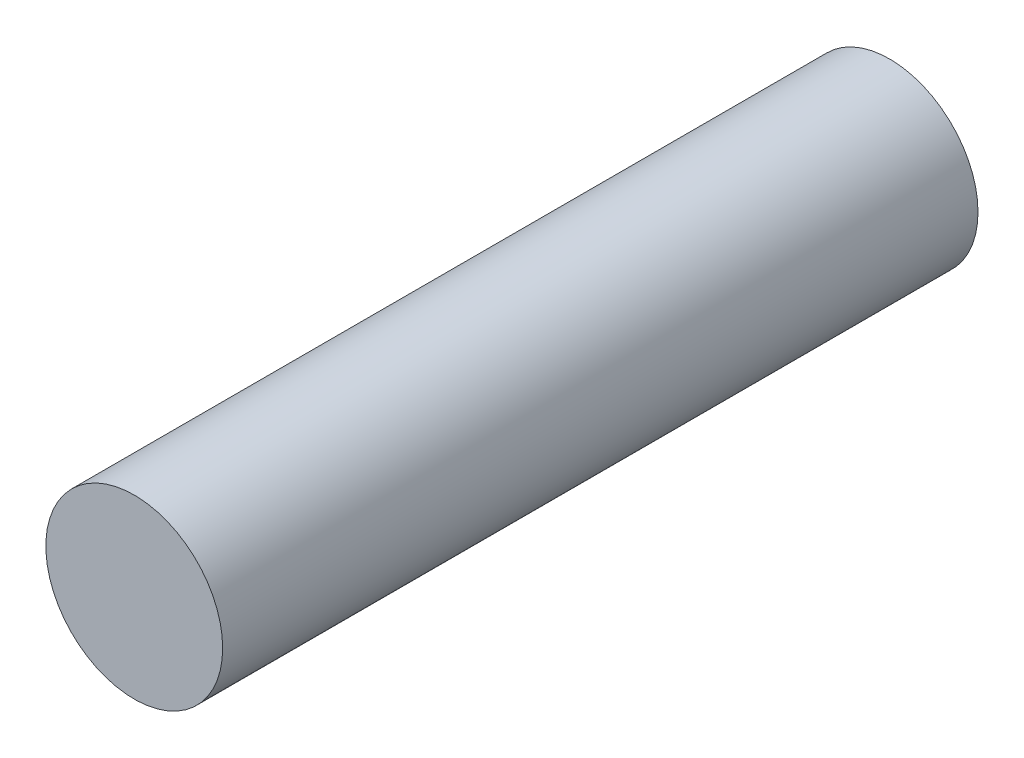
from build123d import *

# Parameters (mm, degrees)
SKETCH1_R      = 5.15
EXTRUDE1_DEPTH = 44


with BuildPart() as part:
    # Sketch1 → Extrude1 (new body)
    with BuildSketch(Plane.XY):
        Circle(SKETCH1_R)
    extrude(amount=EXTRUDE1_DEPTH)


solid = part.part
